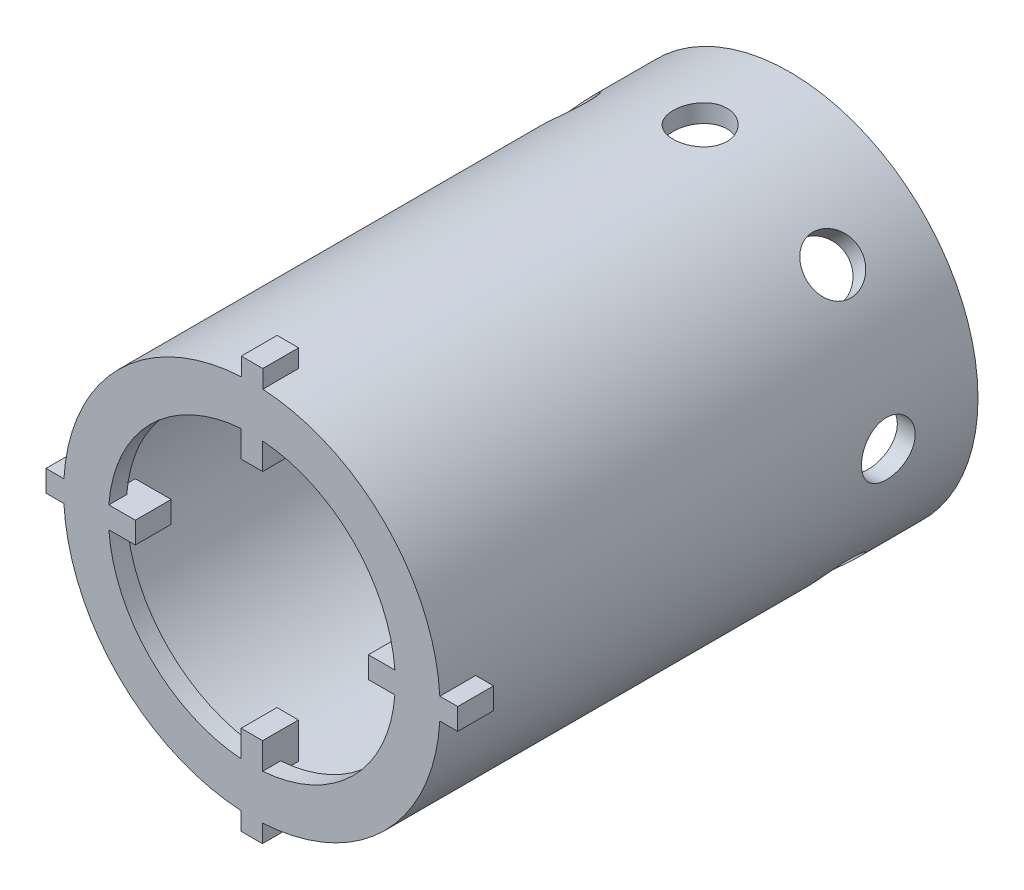
from build123d import *

# Parameters (mm, degrees)
EXTRUDE_START            = 10
SKETCH_1_R               = 10.5
SKETCH_1_R_2             = 9.5
EXTRUDE_1_DEPTH          = 30
EXTRUDE_START_2          = 40
SKETCH_6_R               = 10
SKETCH_6_R_2             = 8
EXTRUDE_3_DEPTH          = 1
SKETCH_5_W               = 2
SKETCH_5_H               = 1.2
EXTRUDE_4_DEPTH          = 2
PATTERN_CIRCULAR_1_COUNT = 4
SKETCH_7_R               = 1.5
CUT_EXTRUDE_2_DEPTH      = 20
PATTERN_CIRCULAR_2_COUNT = 8


with BuildPart() as part:
    # ｽｹｯﾁ1 → ﾎﾞｽ - 押し出し1 (new body)
    with BuildSketch(Plane.XY.offset(EXTRUDE_START)):
        Circle(SKETCH_1_R)
        Circle(SKETCH_1_R_2, mode=Mode.SUBTRACT)
    extrude(amount=EXTRUDE_1_DEPTH)

    # ｽｹｯﾁ6 → ﾎﾞｽ - 押し出し3 (add)
    with BuildSketch(Plane.XY.offset(EXTRUDE_START_2)):
        Circle(SKETCH_6_R)
        Circle(SKETCH_6_R_2, mode=Mode.SUBTRACT)
    extrude(amount=-EXTRUDE_3_DEPTH)

    # ｽｹｯﾁ5 → ﾎﾞｽ - 押し出し4 (add)
    with BuildSketch(Plane.XY.offset(40)):
        with Locations((7.5, 0)):
            Rectangle(SKETCH_5_W, SKETCH_5_H)
        with Locations((10.48172138, -0.010967172)):
            Rectangle(SKETCH_5_W, SKETCH_5_H)
    extrude_4 = extrude(amount=-EXTRUDE_4_DEPTH)

    # 円形ﾊﾟﾀｰﾝ1: ﾎﾞｽ - 押し出し4 ×4 about axis
    pattern_circular_1_axis = Axis((0, 0, 0), (0, 0, 1))
    for i in range(1, PATTERN_CIRCULAR_1_COUNT):
        add(extrude_4.rotate(pattern_circular_1_axis, i * 360 / PATTERN_CIRCULAR_1_COUNT))

    # ｽｹｯﾁ7 → ｶｯﾄ - 押し出し2 (cut, symmetric)
    with BuildSketch(Plane(origin=(0, 0, 0), x_dir=(0, 0, -1), z_dir=(1, 0, 0))):
        with Locations((-15, 0)):
            Circle(SKETCH_7_R)
    cut_extrude_2 = extrude(amount=CUT_EXTRUDE_2_DEPTH, both=True, mode=Mode.SUBTRACT)

    # 円形ﾊﾟﾀｰﾝ2: ｶｯﾄ - 押し出し2 ×8 about axis
    pattern_circular_2_axis = Axis((0, 0, 39), (0, 0, 1))
    for i in range(1, PATTERN_CIRCULAR_2_COUNT):
        add(cut_extrude_2.rotate(pattern_circular_2_axis, i * 360 / PATTERN_CIRCULAR_2_COUNT), mode=Mode.SUBTRACT)


solid = part.part
